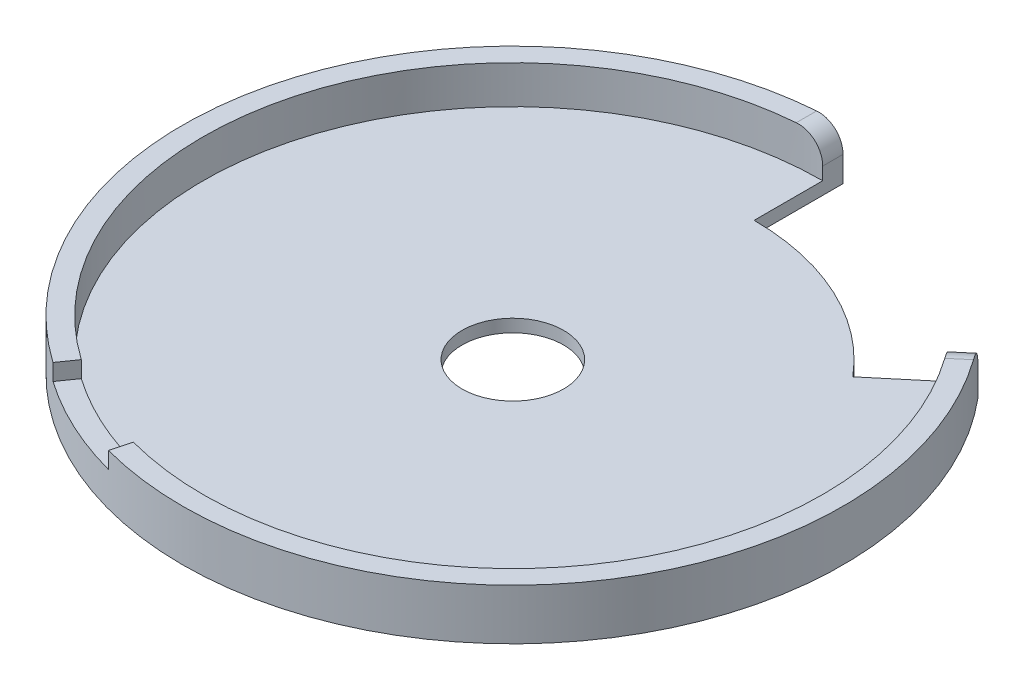
from build123d import *

# Parameters (mm, degrees)
CROQUIS1_R              = 260
CROQUIS1_R_2            = 40
SALIENTE_EXTRUIR1_DEPTH = 10
CROQUIS2_R              = 260
CROQUIS2_R_2            = 244
SALIENTE_EXTRUIR2_DEPTH = 30
CORTAR_EXTRUIR1_DEPTH   = 370.864840178
REDONDEO1_R             = 20
CORTAR_EXTRUIR2_DEPTH   = 13


with BuildPart() as part:
    # Croquis1 → Saliente-Extruir1 (new body)
    with BuildSketch(Plane(origin=(0, 0, 0), x_dir=(1, 0, 0), z_dir=(0, 1, 0))):
        with Locations(Location((0, 0, 0), (0, 0, 270))):
            Circle(CROQUIS1_R)
        with Locations(Location((0, 0, 0), (0, 0, 270))):
            Circle(CROQUIS1_R_2, mode=Mode.SUBTRACT)
    extrude(amount=SALIENTE_EXTRUIR1_DEPTH)

    # Croquis2 → Saliente-Extruir2 (add)
    with BuildSketch(Plane(origin=(0, 10, 0), x_dir=(1, 0, 0), z_dir=(0, 1, 0))):
        with Locations(Location((0, 0, 0), (0, 0, 270))):
            Circle(CROQUIS2_R)
        with Locations(Location((0, 0, 0), (0, 0, 270))):
            Circle(CROQUIS2_R_2, mode=Mode.SUBTRACT)
    extrude(amount=SALIENTE_EXTRUIR2_DEPTH)

    # Croquis3 → Cortar-Extruir1 (cut, through all)
    with BuildSketch(Plane(origin=(0, 40, 0), x_dir=(1, 0, 0), z_dir=(0, 1, 0))):
        with BuildLine():
            ThreePointArc((0, 190), (80.297469731, 172.198479537), (145.548444193, 122.12964584))
            Line((145.548444193, 122.12964584), (199.171555211, 167.124778518))
            ThreePointArc((199.171555211, 167.124778518), (109.880748053, 235.64002463), (0, 260))
            Line((0, 260), (0, 190))
        make_face()
    extrude(amount=-CORTAR_EXTRUIR1_DEPTH, mode=Mode.SUBTRACT)

    # Redondeo1
    redondeo1_edges = [part.edges().sort_by_distance(p)[0] for p in [
        (0, 40, -252),
        (193.043199666, 40, -161.982477641),
    ]]
    fillet(redondeo1_edges, radius=REDONDEO1_R)

    # Croquis4 → Cortar-Extruir2 (cut)
    with BuildSketch(Plane(origin=(0, 40, 0), x_dir=(1, 0, 0), z_dir=(0, 1, 0))):
        with BuildLine():
            Line((-139.95265047, -199.873098807), (-149.129873451, -212.979531515))
            ThreePointArc((-149.129873451, -212.979531515), (-109.880748053, -235.64002463), (-67.292951727, -251.140714835))
            Line((-67.292951727, -251.140714835), (-63.151847005, -235.685901615))
            ThreePointArc((-63.151847005, -235.685901615), (-103.118855865, -221.139100037), (-139.95265047, -199.873098807))
        make_face()
    extrude(amount=-CORTAR_EXTRUIR2_DEPTH, mode=Mode.SUBTRACT)


solid = part.part
